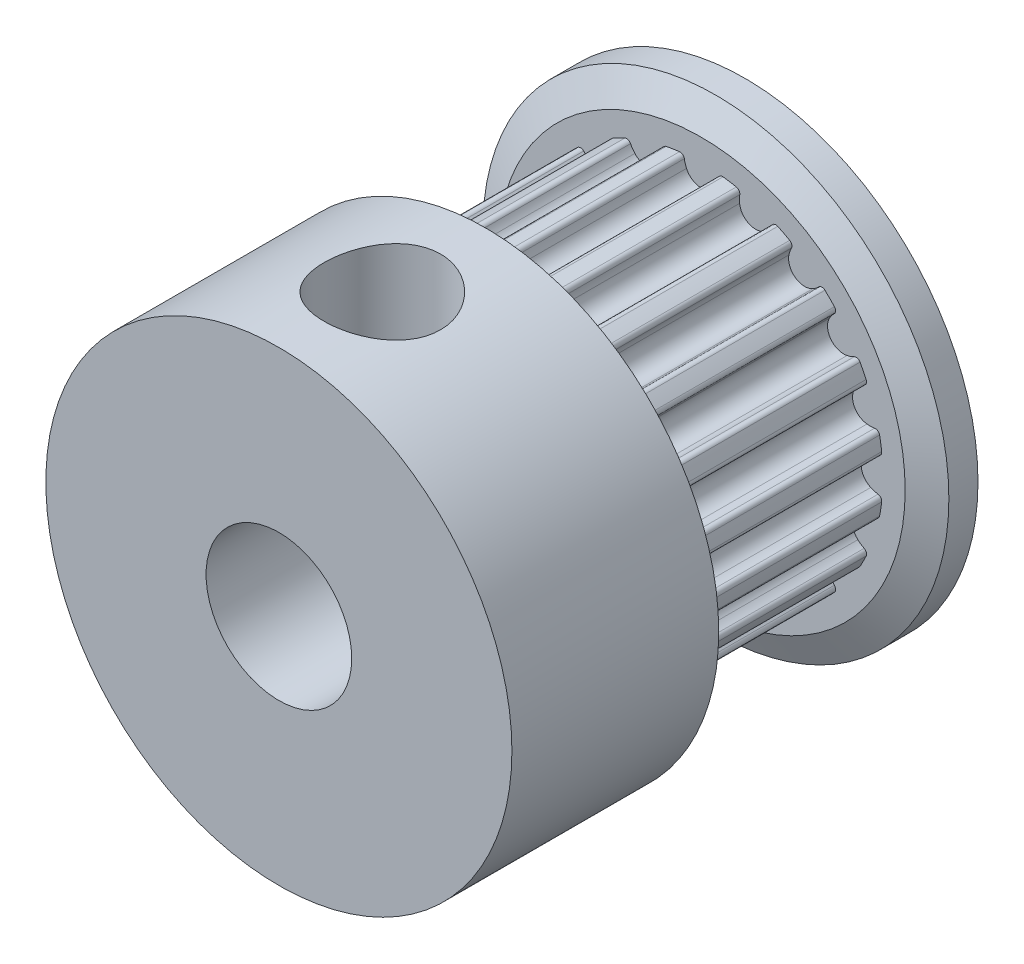
from build123d import *

# Parameters (mm, degrees)
SKETCH1_R            = 6.366
BASE_DEPTH           = 7.4
TOOTHCUT_DEPTH       = 8.4
TEETHCUTS_COUNT      = 20
SKETCH3_W            = 8
SKETCH3_H            = 7.1
SKETCH4_R            = 2.5
SHAFTHOLE_DEPTH      = 15.5
SHAFTHOLE_DEPTH_BACK = 2.5
SKETCH5_R            = 2
FIXINGHOLE_DEPTH     = 9


with BuildPart() as part:
    # Sketch1 → Base (new body)
    with BuildSketch(Plane.XY):
        Circle(SKETCH1_R)
    extrude(amount=BASE_DEPTH)

    # Sketch2 → ToothCut (cut, through all)
    with BuildSketch(Plane.XY.offset(7.4)):
        with BuildLine():
            Line((-0.975994627, 6.162187557), (-0.995861804, 6.287623976))
            ThreePointArc((-0.995861804, 6.287623976), (0, 6.366), (0.995861804, 6.287623976))
            Line((0.995861804, 6.287623976), (0.975994627, 6.162187557))
            ThreePointArc((0.975994627, 6.162187557), (0.861900832, 6.179178583), (0.747512406, 6.19405733))
            ThreePointArc((0.747512406, 6.19405733), (0.639182458, 6.164868505), (0.581402261, 6.068697753))
            ThreePointArc((0.581402261, 6.068697753), (0.552274653, 5.940538449), (0.506591342, 5.817305906))
            ThreePointArc((0.506591342, 5.817305906), (0, 5.489), (-0.506591342, 5.817305906))
            ThreePointArc((-0.506591342, 5.817305906), (-0.552274653, 5.940538449), (-0.581402261, 6.068697753))
            ThreePointArc((-0.581402261, 6.068697753), (-0.639182458, 6.164868505), (-0.747512406, 6.19405733))
            ThreePointArc((-0.747512406, 6.19405733), (-0.861900832, 6.179178583), (-0.975994627, 6.162187557))
        make_face()
    toothcut = extrude(amount=-TOOTHCUT_DEPTH, mode=Mode.SUBTRACT)

    # TeethCuts: ToothCut ×20 about axis
    teethcuts_axis = Axis((0, 0, 0), (0, 0, 1))
    for i in range(1, TEETHCUTS_COUNT):
        add(toothcut.rotate(teethcuts_axis, i * 360 / TEETHCUTS_COUNT), mode=Mode.SUBTRACT)

    # Sketch3 → Body (revolve)
    with BuildSketch(Plane(origin=(0, 0, 0), x_dir=(1, 0, 0), z_dir=(0, 1, 0))):
        Polygon((0, 0), (0, 1.5), (-8, 1.5), (-8, 0.5), (-7, 0), align=None)
        with Locations((-4, -10.95)):
            Rectangle(SKETCH3_W, SKETCH3_H)
    revolve(axis=Axis((0, 0, 14.5), (0, 0, -1)))

    # Sketch4 → ShaftHole (cut, two sides)
    with BuildSketch(Plane.XY) as shafthole_sk:
        Circle(SKETCH4_R)
    extrude(amount=SHAFTHOLE_DEPTH, mode=Mode.SUBTRACT)
    extrude(shafthole_sk.sketch, amount=-SHAFTHOLE_DEPTH_BACK, mode=Mode.SUBTRACT)

    # Sketch5 → FixingHole (cut, through all)
    with BuildSketch(Plane(origin=(0, 0, 0), x_dir=(1, 0, 0), z_dir=(0, 1, 0))):
        with Locations((0, -10.95)):
            Circle(SKETCH5_R)
    extrude(amount=FIXINGHOLE_DEPTH, mode=Mode.SUBTRACT)


solid = part.part
